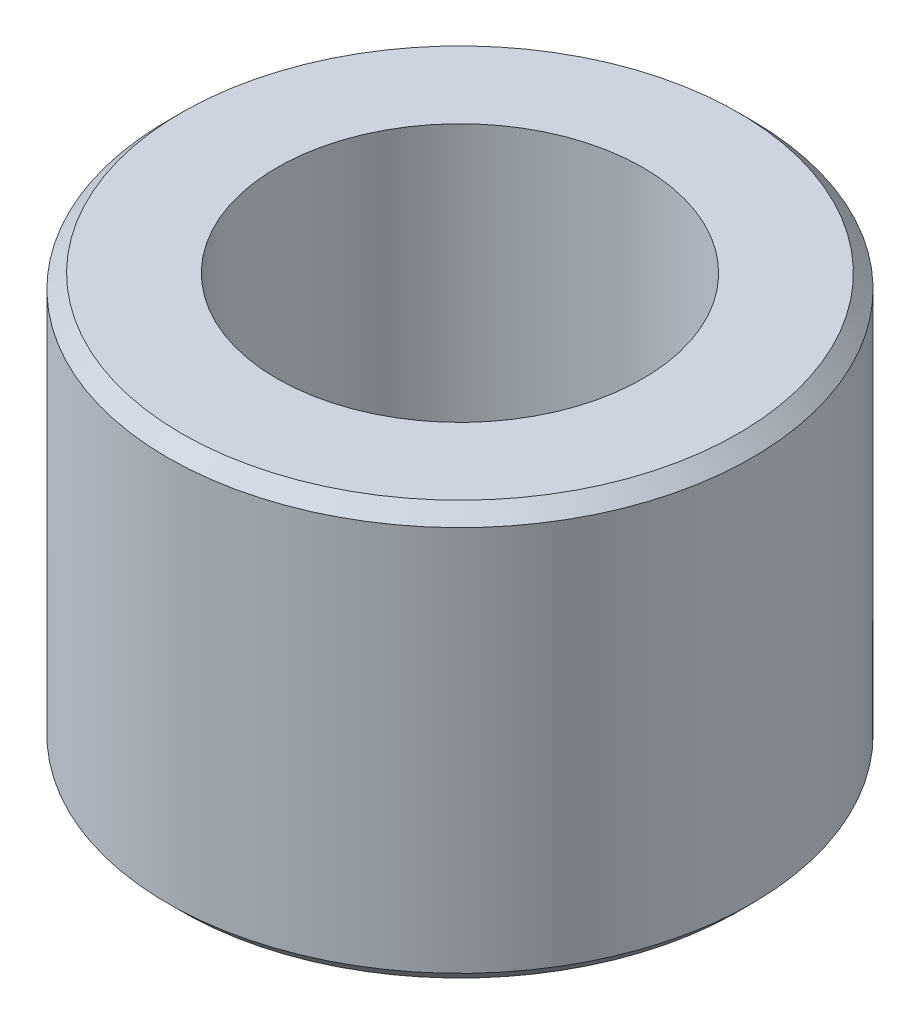
from build123d import *

# Parameters (mm, degrees)
SKETCH1_W     = 3.9878
SKETCH1_H     = 15.113
CHAMFER1_SIZE = 0.508


with BuildPart() as part:
    # Sketch1 → Revolve1 (revolve)
    with BuildSketch(Plane.XY):
        with Locations((8.6741, -7.5565)):
            Rectangle(SKETCH1_W, SKETCH1_H)
    revolve(axis=Axis((0, 0, 0), (0, -1, 0)))

    # Chamfer1
    chamfer1_edges = [part.edges().sort_by_distance(p)[0] for p in [
        (-10.668, -15.113, 0),
        (-10.668, 0, 0),
    ]]
    chamfer(chamfer1_edges, length=CHAMFER1_SIZE)


solid = part.part
